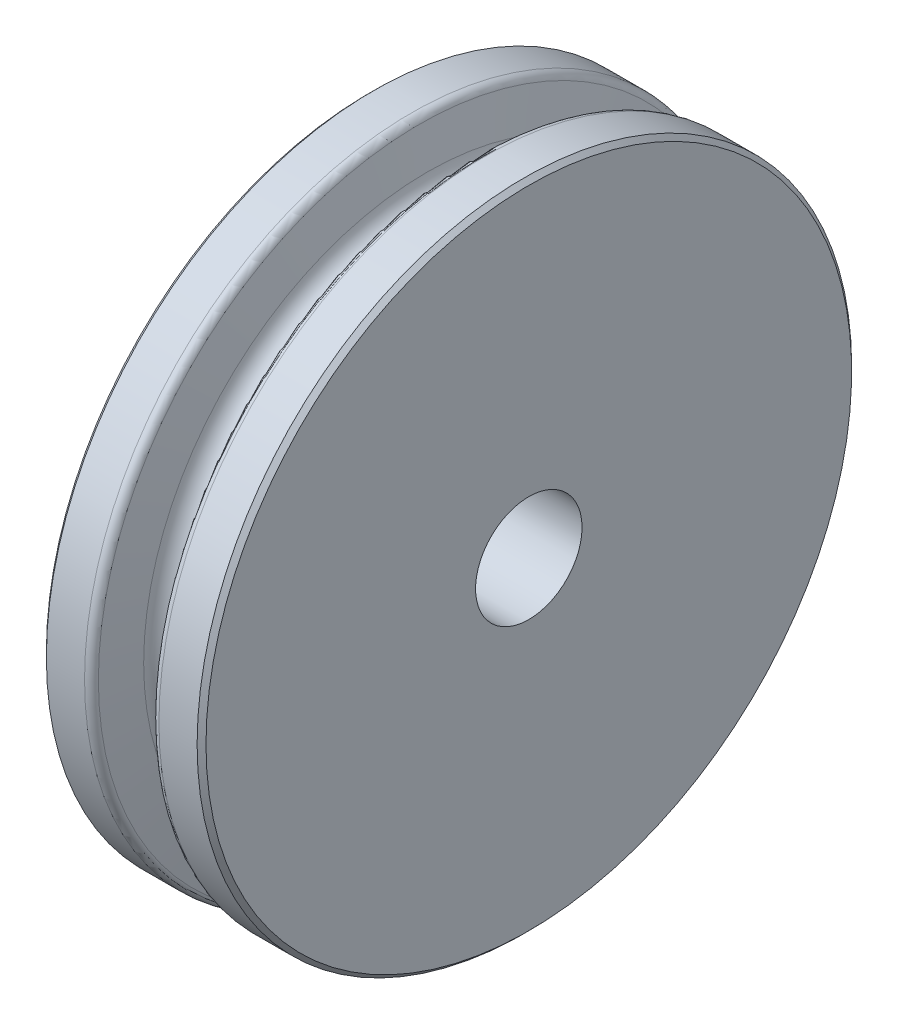
from build123d import *

# Parameters (mm, degrees)
SKETCH2_R          = 9.53135
CUT_EXTRUDE1_DEPTH = 29.575


with BuildPart() as part:
    # Sketch1 → Revolve1 (revolve)
    with BuildSketch(Plane.XY, mode=Mode.PRIVATE) as revolve1_sk:
        with BuildLine():
            Line((-14.2875, 0), (14.2875, 0))
            Line((14.2875, 0), (14.2875, 57.793141026))
            Line((14.2875, 57.793141026), (13.49375, 58.586891026))
            Line((13.49375, 58.586891026), (6.659344616, 58.586891026))
            ThreePointArc((6.659344616, 58.586891026), (5.778331049, 58.274323253), (5.291300439, 57.476398003))
            Line((5.291300439, 57.476398003), (3.883957867, 50.777754993))
            ThreePointArc((3.883957867, 50.777754993), (0, 47.625), (-3.883957867, 50.777754993))
            Line((-3.883957867, 50.777754993), (-5.291300439, 57.476398003))
            ThreePointArc((-5.291300439, 57.476398003), (-5.778331049, 58.274323253), (-6.659344616, 58.586891026))
            Line((-6.659344616, 58.586891026), (-13.49375, 58.586891026))
            Line((-13.49375, 58.586891026), (-14.2875, 57.793141026))
            Line((-14.2875, 57.793141026), (-14.2875, 0))
        make_face()
    revolve(revolve1_sk.sketch.rotate(Axis((-14.2875, 0, 0), (1, 0, 0)), 90), axis=Axis((-14.2875, 0, 0), (1, 0, 0)))  # turned: the seam where the file's is

    # Sketch2 → Cut-Extrude1 (cut, through all)
    with BuildSketch(Plane(origin=(14.2875, 0, 0), x_dir=(0, 0, -1), z_dir=(1, 0, 0))):
        Circle(SKETCH2_R)
    extrude(amount=-CUT_EXTRUDE1_DEPTH, mode=Mode.SUBTRACT)


solid = part.part
